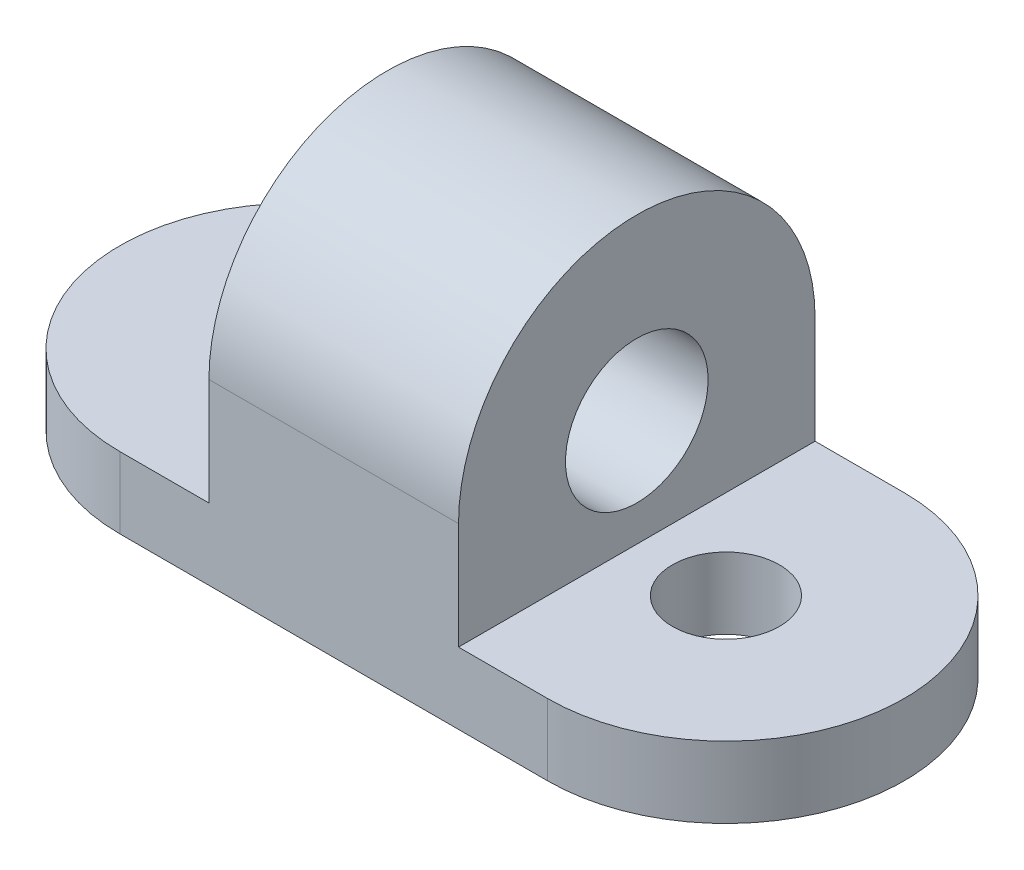
from build123d import *

# Parameters (mm, degrees)
SKETCH1_R           = 9.525
BOSS_EXTRUDE2_DEPTH = 12.7
SKETCH2_W           = 44.45
SKETCH2_H           = 63.5
BOSS_EXTRUDE3_DEPTH = 19.05
BOSS_EXTRUDE4_DEPTH = 44.45
SKETCH4_R           = 12.7
CUT_EXTRUDE1_DEPTH  = 44.45


with BuildPart() as part:
    # Sketch1 → Boss-Extrude2 (new body)
    with BuildSketch(Plane(origin=(0, 0, 0), x_dir=(1, 0, 0), z_dir=(0, 1, 0))):
        with BuildLine():
            Line((-38.1, 31.75), (38.1, 31.75))
            ThreePointArc((38.1, 31.75), (69.85, 0), (38.1, -31.75))
            Line((38.1, -31.75), (-38.1, -31.75))
            ThreePointArc((-38.1, -31.75), (-69.85, 0), (-38.1, 31.75))
        make_face()
        with Locations((-38.1, 0)):
            Circle(SKETCH1_R, mode=Mode.SUBTRACT)
        with Locations((38.1, 0)):
            Circle(SKETCH1_R, mode=Mode.SUBTRACT)
    extrude(amount=BOSS_EXTRUDE2_DEPTH)

    # Sketch2 → Boss-Extrude3 (add)
    with BuildSketch(Plane(origin=(0, 12.7, 0), x_dir=(1, 0, 0), z_dir=(0, 1, 0))):
        Rectangle(SKETCH2_W, SKETCH2_H)
    extrude(amount=BOSS_EXTRUDE3_DEPTH)

    # Sketch3 → Boss-Extrude4 (add)
    with BuildSketch(Plane(origin=(22.225, 0, 0), x_dir=(0, 0, -1), z_dir=(1, 0, 0))):
        with BuildLine():
            Line((-31.75, 12.7), (31.75, 12.7))
            Line((31.75, 12.7), (31.75, 31.75))
            ThreePointArc((31.75, 31.75), (0, 63.5), (-31.75, 31.75))
            Line((-31.75, 31.75), (-31.75, 12.7))
        make_face()
    extrude(amount=-BOSS_EXTRUDE4_DEPTH)

    # Sketch4 → Cut-Extrude1 (cut)
    with BuildSketch(Plane(origin=(22.225, 0, 0), x_dir=(0, 0, -1), z_dir=(1, 0, 0))):
        with Locations((0, 31.75)):
            Circle(SKETCH4_R)
    extrude(amount=-CUT_EXTRUDE1_DEPTH, mode=Mode.SUBTRACT)


solid = part.part
